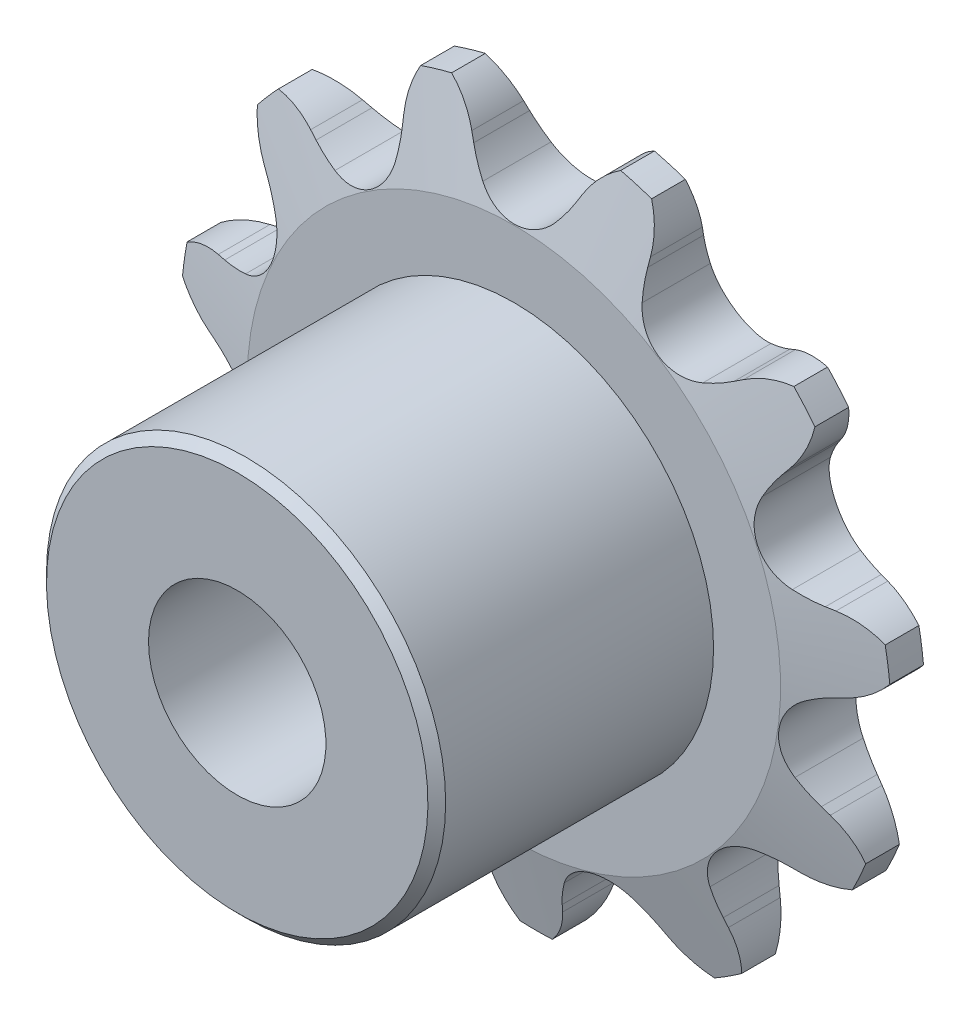
from build123d import *

# Parameters (mm, degrees)
CUT_EXTRUDE1_DEPTH      = 19.040220505
CIRPATTERN1_COUNT       = 11
BOSS_EXTRUDE1_START     = 1.397
SKETCH2_R               = 7.14375
BOSS_EXTRUDE1_DEPTH     = 9.906
CUT_EXTRUDE2_DEPTH      = 22.206719511
CUT_EXTRUDE2_DEPTH_BACK = 22.206719511
SKETCH3_R               = 3.175
SKETCH4_W               = 2.0955
SKETCH4_H               = 5.461


with BuildPart() as part:
    # Sketch1 → Revolve1 (revolve)
    with BuildSketch(Plane(origin=(0, 0, 0), x_dir=(0, 0, -1), z_dir=(1, 0, 0)), mode=Mode.PRIVATE) as revolve1_sk:
        Polygon((1.397, 0), (-1.397, 0), (-1.397, 9.543056983), (-0.60325, 12.718056983), (0.60325, 12.718056983), (1.397, 9.543056983), align=None)
    revolve(revolve1_sk.sketch.rotate(Axis((0, 0, -1.397), (0, 0, 1)), 90), axis=Axis((0, 0, -1.397), (0, 0, 1)))

    # Sketch0 → Cut-Extrude1 (cut, symmetric)
    with BuildSketch(Plane.XY):
        with BuildLine():
            Line((5.067658792, -10.235463679), (4.855219932, -10.014777134))
            ThreePointArc((4.855219932, -10.014777134), (4.49713377, -9.6824462), (4.103958425, -9.392476032))
            ThreePointArc((4.103958425, -9.392476032), (2.696799836, -9.184456787), (1.625486396, -10.120221082))
            ThreePointArc((1.625486396, -10.120221082), (1.451495957, -10.576726149), (1.329926375, -11.049896717))
            Line((1.329926375, -11.049896717), (1.270523588, -11.350403172))
            ThreePointArc((1.270523588, -11.350403172), (0.16506158, -13.06621068), (-1.815527736, -13.559472897))
            ThreePointArc((-1.815527736, -13.559472897), (3.854235715, -13.126321391), (8.858123633, -10.425406079))
            ThreePointArc((8.858123633, -10.425406079), (6.925268185, -11.081234923), (5.067658792, -10.235463679))
        make_face()
    cut_extrude1 = extrude(amount=CUT_EXTRUDE1_DEPTH, both=True, mode=Mode.SUBTRACT)

    # CirPattern1: Cut-Extrude1 ×11 about axis
    cirpattern1_axis = Axis((0, 0, 0), (0, 0, 1))
    for i in range(1, CIRPATTERN1_COUNT):
        add(cut_extrude1.rotate(cirpattern1_axis, i * 360 / CIRPATTERN1_COUNT), mode=Mode.SUBTRACT)

    # Sketch2 → Boss-Extrude1 (add)
    with BuildSketch(Plane.XY.offset(BOSS_EXTRUDE1_START)):
        Circle(SKETCH2_R)
    extrude(amount=BOSS_EXTRUDE1_DEPTH)

    # Sketch3 → Cut-Extrude2 (cut, two sides: drawn at the far end of the back side and taken through both)
    with BuildSketch(Plane.XY.offset(-CUT_EXTRUDE2_DEPTH_BACK)):
        with Locations(Location((0, 0, 0), (0, 0, 180))):
            Circle(SKETCH3_R)
    extrude(amount=CUT_EXTRUDE2_DEPTH + CUT_EXTRUDE2_DEPTH_BACK, mode=Mode.SUBTRACT)

    # Sketch4 → Cut-Revolve1 (revolve, cut)
    with BuildSketch(Plane(origin=(0, 0, 0), x_dir=(0, 0, -1), z_dir=(1, 0, 0))):
        Polygon((-11.303, 7.14375), (-11.303, 6.82625), (-10.9855, 7.14375), align=None)
        with Locations((-2.44475, 9.987556983)):
            Rectangle(SKETCH4_W, SKETCH4_H)
    revolve(axis=Axis((0, 0, -1.397), (0, 0, 1)), mode=Mode.SUBTRACT)


solid = part.part
